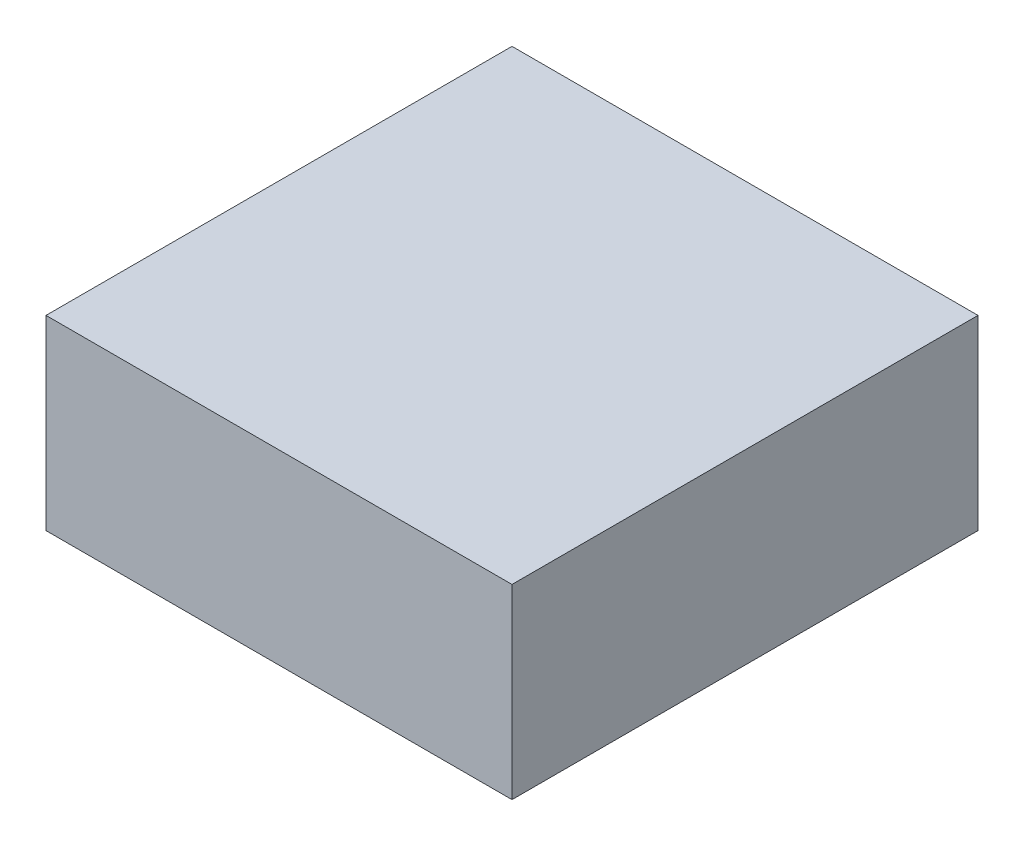
from build123d import *

# Parameters (mm, degrees)
SKETCH1_W           = 15.875
SKETCH1_H           = 15.875
BOSS_EXTRUDE1_DEPTH = 6.35


with BuildPart() as part:
    # Sketch1 → Boss-Extrude1 (new body)
    with BuildSketch(Plane(origin=(0, 0, 0), x_dir=(1, 0, 0), z_dir=(0, 1, 0))):
        with Locations((7.9375, 7.9375)):
            Rectangle(SKETCH1_W, SKETCH1_H)
    extrude(amount=BOSS_EXTRUDE1_DEPTH)


solid = part.part
